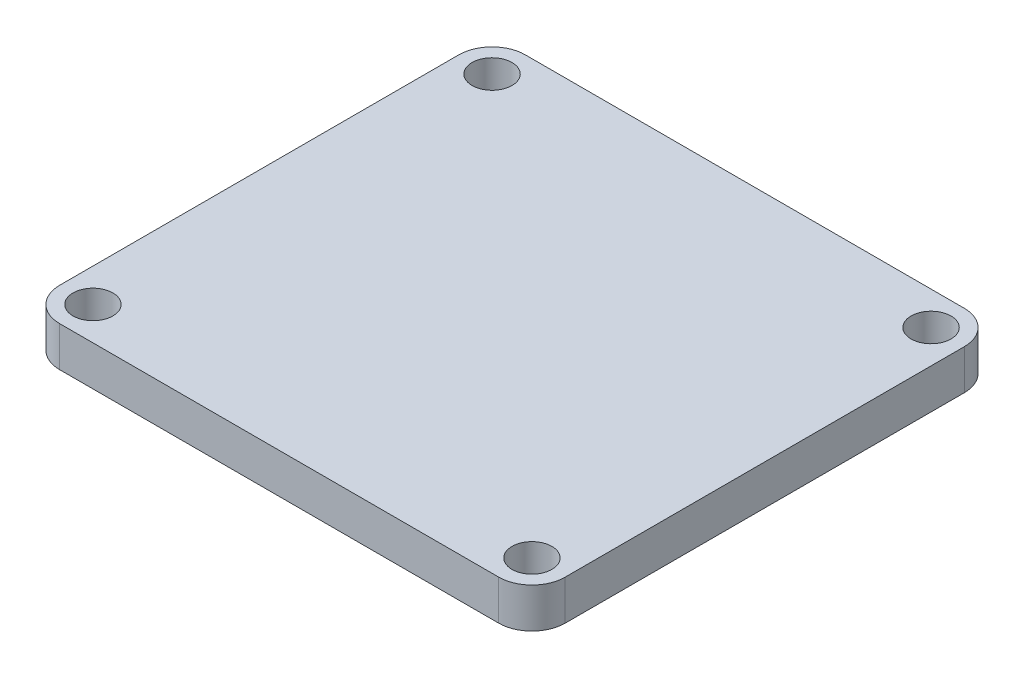
from build123d import *

# Parameters (mm, degrees)
SKETCH2_R           = 3
BOSS_EXTRUDE1_DEPTH = 6


with BuildPart() as part:
    # Sketch2 → Boss-Extrude1 (new body)
    with BuildSketch(Plane(origin=(0, 0, 0), x_dir=(1, 0, 0), z_dir=(0, 1, 0))):
        with BuildLine():
            Line((-33, -35), (33, -35))
            ThreePointArc((33, -35), (36.535533906, -33.535533906), (38, -30))
            Line((38, -30), (38, 30))
            ThreePointArc((38, 30), (36.535533906, 33.535533906), (33, 35))
            Line((33, 35), (-33, 35))
            ThreePointArc((-33, 35), (-36.535533906, 33.535533906), (-38, 30))
            Line((-38, 30), (-38, -30))
            ThreePointArc((-38, -30), (-36.535533906, -33.535533906), (-33, -35))
        make_face()
        with Locations((-33, 30)):
            Circle(SKETCH2_R, mode=Mode.SUBTRACT)
        with Locations((-33, -30)):
            Circle(SKETCH2_R, mode=Mode.SUBTRACT)
        with Locations((33, 30)):
            Circle(SKETCH2_R, mode=Mode.SUBTRACT)
        with Locations((33, -30)):
            Circle(SKETCH2_R, mode=Mode.SUBTRACT)
    extrude(amount=BOSS_EXTRUDE1_DEPTH)


solid = part.part
